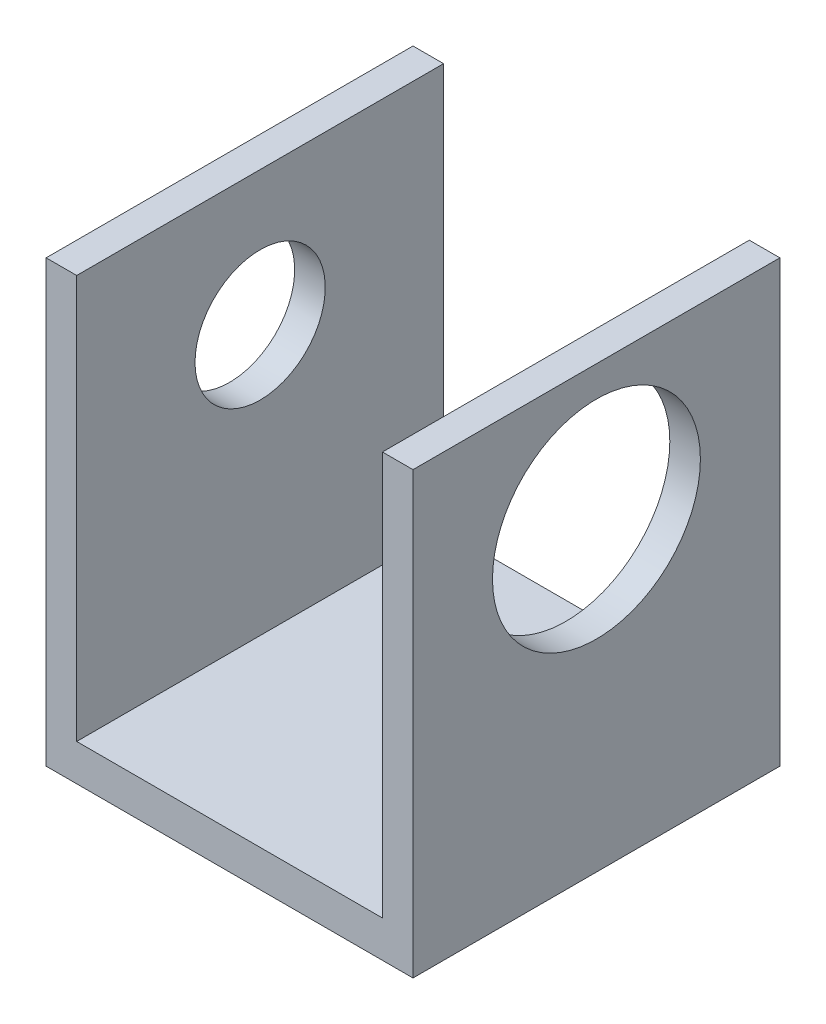
from build123d import *

# Parameters (mm, degrees)
BOSS_EXTRUDE1_DEPTH       = 7.62
F_6_32_TAPPED_HOLE1_D     = 2.7051
F_6_32_TAPPED_HOLE1_DEPTH = 0.635
CUT_EXTRUDE1_REACH        = 9.62
SKETCH6_R                 = 2.159


with BuildPart() as part:
    # Sketch1 → Boss-Extrude1 (new body)
    with BuildSketch(Plane.XY):
        Polygon((-3.353873239, 6.85218662), (-3.353873239, -2.29181338), (4.266126761, -2.29181338), (4.266126761, 6.85218662), (3.631126761, 6.85218662), (3.631126761, -1.52981338), (-2.718873239, -1.52981338), (-2.718873239, 6.85218662), align=None)
    extrude(amount=BOSS_EXTRUDE1_DEPTH)

    # #6-32 Tapped Hole1
    with Locations(Plane.ZY.offset(3.353873239)):
        with Locations((3.81, 4.05818662)):
            Hole(F_6_32_TAPPED_HOLE1_D / 2, depth=F_6_32_TAPPED_HOLE1_DEPTH)

    # Sketch6 → Cut-Extrude1 (cut, up to next)
    with BuildSketch(Plane(origin=(4.266126761, 0, 0), x_dir=(0, 0, -1), z_dir=(1, 0, 0)), mode=Mode.PRIVATE) as cut_extrude1_sk1:
        with Locations((-3.81, 4.05818662)):
            Circle(SKETCH6_R)
    cut_extrude1_tool1 = extrude(cut_extrude1_sk1.sketch, amount=-CUT_EXTRUDE1_REACH, mode=Mode.PRIVATE) & part.part
    add(cut_extrude1_tool1.solids().sort_by_distance((4.266127, 4.058187, 3.81))[0], mode=Mode.SUBTRACT)


solid = part.part
